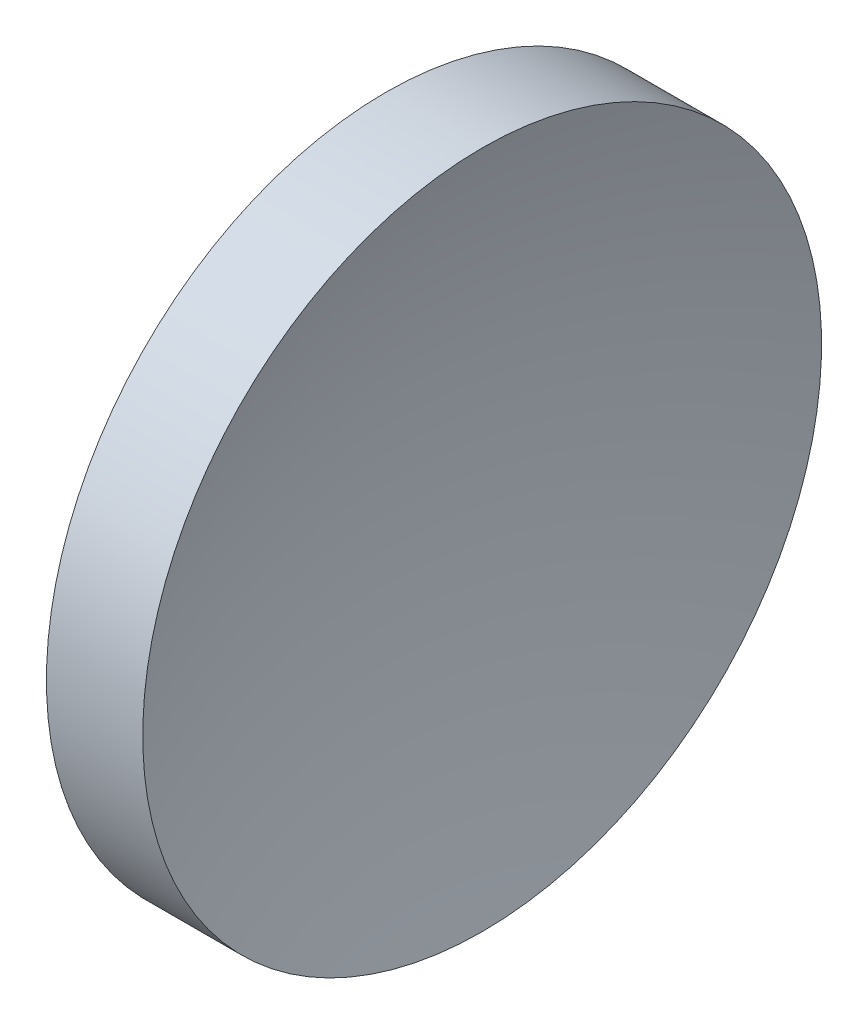
from build123d import *


with BuildPart() as part:
    # 草图1 → 旋转1 (revolve)
    with BuildSketch(Plane.XY, mode=Mode.PRIVATE) as revolve_1_sk:
        with BuildLine():
            Line((114.97544726, 65.157451827), (114.97544726, 85.157451827))
            Line((114.97544726, 85.157451827), (120.651979298, 85.157451827))
            ThreePointArc((120.651979298, 85.157451827), (118.274526122, 75.282795741), (117.47544726, 65.157451827))
            Line((117.47544726, 65.157451827), (114.97544726, 65.157451827))
        make_face()
    revolve(revolve_1_sk.sketch.rotate(Axis((110.014789249, 65.157451827, 0), (1, 0, 0)), 180), axis=Axis((110.014789249, 65.157451827, 0), (1, 0, 0)))  # turned: the seam where the file's is


solid = part.part
